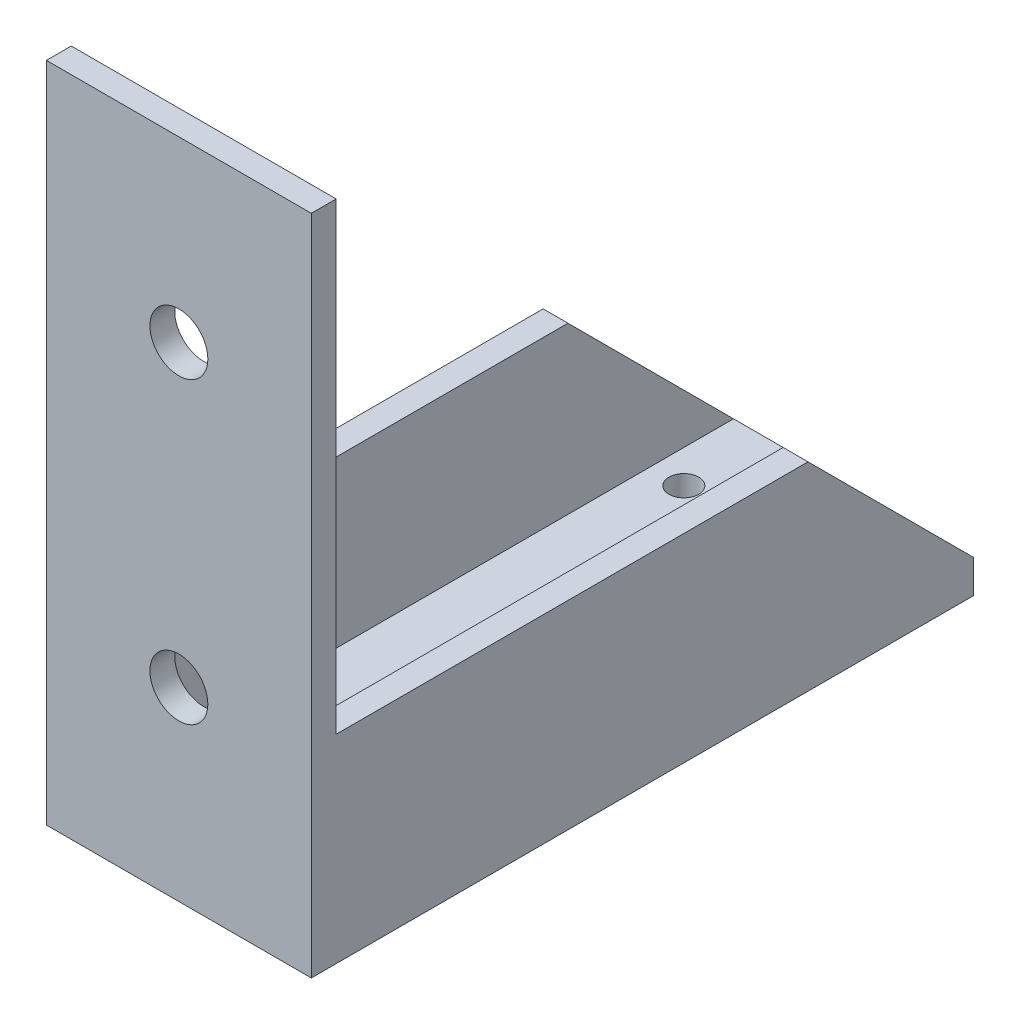
from build123d import *

# Parameters (mm, degrees)
SKETCH1_W           = 16
SKETCH1_H           = 40
SKETCH1_R           = 2.3
SKETCH1_R_2         = 0.9
BOSS_EXTRUDE1_DEPTH = 2
BOSS_EXTRUDE2_DEPTH = 1.5
BOSS_EXTRUDE3_DEPTH = 1.5
SKETCH4_W           = 16
SKETCH4_H           = 40
SKETCH4_R           = 1.75
BOSS_EXTRUDE4_DEPTH = 1.5


with BuildPart() as part:
    # Sketch1 → Boss-Extrude1 (new body)
    with BuildSketch(Plane(origin=(0, 0, 0), x_dir=(1, 0, 0), z_dir=(0, 1, 0))):
        with Locations((8, 20)):
            Rectangle(SKETCH1_W, SKETCH1_H)
        with Locations((8, 35)):
            Circle(SKETCH1_R, mode=Mode.SUBTRACT)
        with Locations((3.5, 35)):
            Circle(SKETCH1_R_2, mode=Mode.SUBTRACT)
        with Locations((12.5, 35)):
            Circle(SKETCH1_R_2, mode=Mode.SUBTRACT)
    extrude(amount=BOSS_EXTRUDE1_DEPTH)

    # Sketch2 → Boss-Extrude2 (add)
    with BuildSketch(Plane.ZY):
        Polygon((-40, 2), (-30, 12), (0, 12), (0, 2), align=None)
    extrude(amount=-BOSS_EXTRUDE2_DEPTH)

    # Sketch3 → Boss-Extrude3 (add)
    with BuildSketch(Plane(origin=(16, 0, -16), x_dir=(0, 0, 1), z_dir=(-1, 0, 0))):
        Polygon((-24, 2), (-14, 12), (16, 12), (16, 2), align=None)
    extrude(amount=BOSS_EXTRUDE3_DEPTH)

    # Sketch4 → Boss-Extrude4 (add)
    with BuildSketch(Plane.XY):
        with Locations((8, 20)):
            Rectangle(SKETCH4_W, SKETCH4_H)
        with Locations((8, 11.197621249)):
            Circle(SKETCH4_R, mode=Mode.SUBTRACT)
        with Locations((8, 29.249612775)):
            Circle(SKETCH4_R, mode=Mode.SUBTRACT)
    extrude(amount=-BOSS_EXTRUDE4_DEPTH)


solid = part.part
